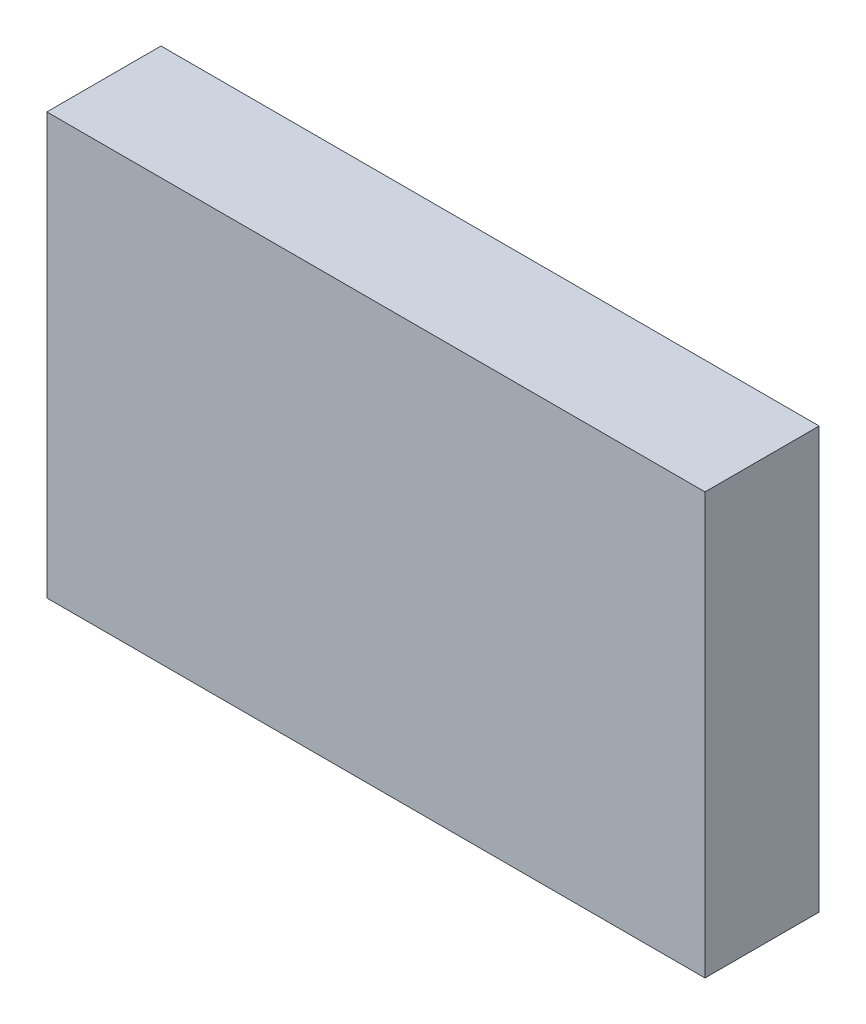
from build123d import *

# Parameters (mm, degrees)
ESQUISSE1_W        = 57.663969182
ESQUISSE1_H        = 36.884525939
BOSS_EXTRU_1_DEPTH = 10


with BuildPart() as part:
    # Esquisse1 → Boss.-Extru.1 (new body)
    with BuildSketch(Plane.XY):
        with Locations((28.831984591, 18.442262969)):
            Rectangle(ESQUISSE1_W, ESQUISSE1_H)
    extrude(amount=BOSS_EXTRU_1_DEPTH)


solid = part.part
